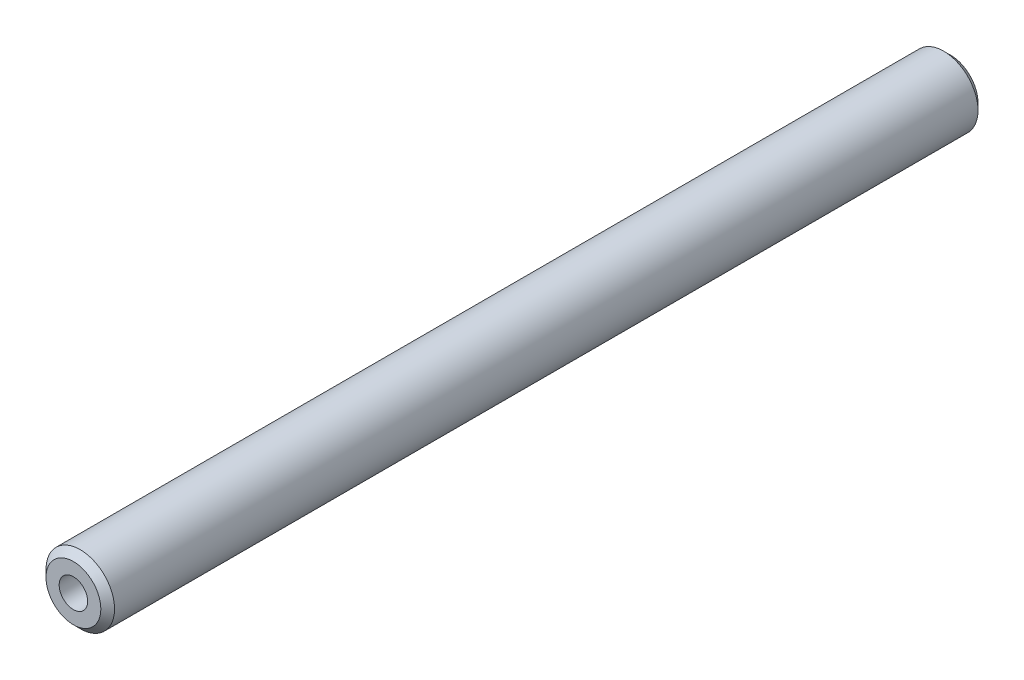
from build123d import *

# Parameters (mm, degrees)
SKETCH3_R           = 3.96875
BOSS_EXTRUDE1_DEPTH = 50.8
CHAMFER1_SIZE       = 0.79375


with BuildPart() as part:
    # Sketch3 → Boss-Extrude1 (new body, symmetric)
    with BuildSketch(Plane.XY):
        Circle(SKETCH3_R)
    extrude(amount=BOSS_EXTRUDE1_DEPTH, both=True)

    # Chamfer1
    chamfer1_edges = [part.edges().sort_by_distance(p)[0] for p in [
        (-3.96875, 0, -50.8),
        (-3.96875, 0, 50.8),
    ]]
    chamfer(chamfer1_edges, length=CHAMFER1_SIZE)

    # Sketch6 → M4x0.7 Tapped Hole1 (revolve, cut)
    with BuildSketch(Plane(origin=(0, 0, -50.8), x_dir=(0, 1, 0), z_dir=(1, 0, 0))):
        Polygon((0, 0), (0, 15.991420021), (1.65, 15), (1.65, 0), align=None)
    m4x0_7_tapped_hole1 = revolve(axis=Axis((0, 0, -57.15), (0, 0, 1)), mode=Mode.SUBTRACT)

    # Mirror1: M4x0.7 Tapped Hole1 across plane
    add(m4x0_7_tapped_hole1.mirror(Plane.XY), mode=Mode.SUBTRACT)


solid = part.part
